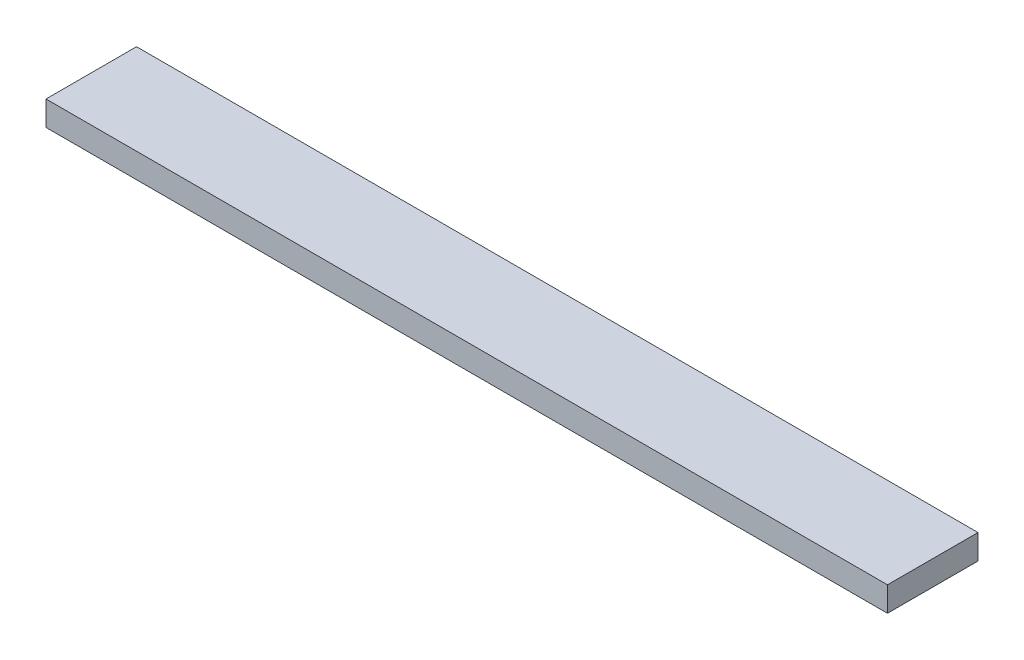
from build123d import *

# Parameters (mm, degrees)
SKETCH1_W           = 649.2875
SKETCH1_H           = 69.85
BOSS_EXTRUDE1_DEPTH = 19.05


with BuildPart() as part:
    # Sketch1 → Boss-Extrude1 (new body)
    with BuildSketch(Plane(origin=(0, 0, 0), x_dir=(1, 0, 0), z_dir=(0, 1, 0))):
        with Locations((324.64375, 34.925)):
            Rectangle(SKETCH1_W, SKETCH1_H)
    extrude(amount=BOSS_EXTRUDE1_DEPTH)


solid = part.part
